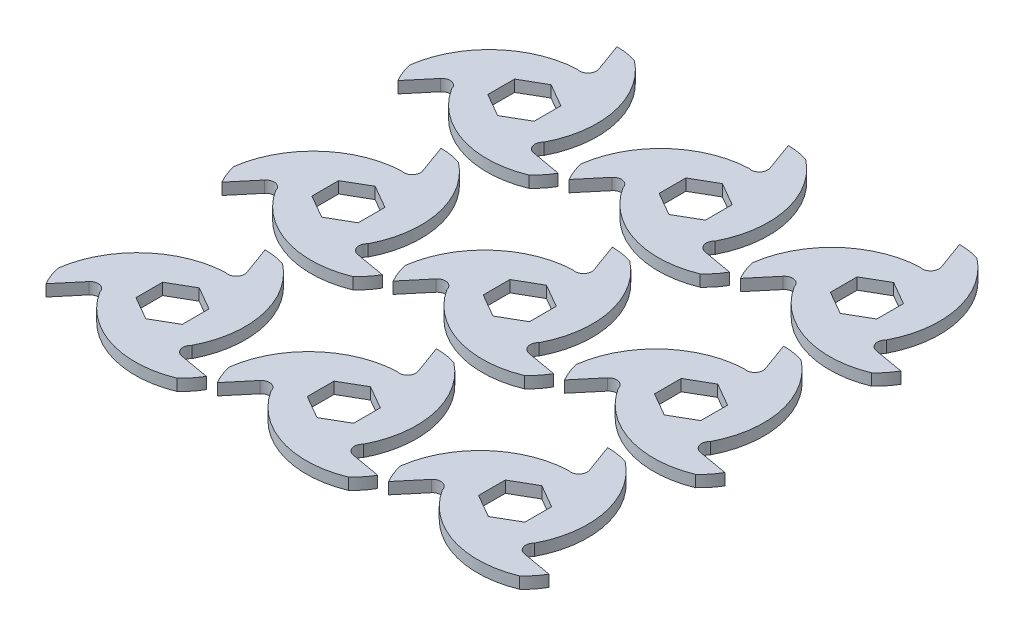
from build123d import *

# Parameters (mm, degrees)
BOSS_EXTRUDE2_DEPTH = 3.175
CUT_EXTRUDE1_DEPTH  = 7.35
LPATTERN1_COUNT     = 3
LPATTERN1_PITCH     = 96.52
LPATTERN1_2_COUNT   = 3
LPATTERN1_2_PITCH   = 93.98


with BuildPart() as part:
    # Sketch2 → Boss-Extrude2 (new body, symmetric)
    with BuildSketch(Plane(origin=(0, 0, 0), x_dir=(1, 0, 0), z_dir=(0, 1, 0))):
        with BuildLine():
            Line((0, 50.8), (5.699182497, 35.141624781))
            ThreePointArc((5.699182497, 35.141624781), (4.697625818, 30.400196659), (0, 29.21))
            ThreePointArc((0, 29.21), (-40.712457699, 16.982230342), (-43.994090512, -25.4))
            Line((-43.994090512, -25.4), (-33.283131039, -12.635175567))
            ThreePointArc((-33.283131039, -12.635175567), (-28.676155496, -11.131835033), (-25.296602045, -14.605))
            ThreePointArc((-25.296602045, -14.605), (5.64918596, -43.749137789), (43.994090512, -25.4))
            Line((43.994090512, -25.4), (27.583948542, -22.506449213))
            ThreePointArc((27.583948542, -22.506449213), (23.978529677, -19.268361626), (25.296602045, -14.605))
            ThreePointArc((25.296602045, -14.605), (35.063271738, 26.766907447), (0, 50.8))
        make_face()
        Polygon((0, 14.664696837), (12.7, 7.332348419), (12.7, -7.332348419), (0, -14.664696837), (-12.7, -7.332348419), (-12.7, 7.332348419), align=None, mode=Mode.SUBTRACT)
    extrude(amount=BOSS_EXTRUDE2_DEPTH, both=True)

    # Sketch3 → Cut-Extrude1 (cut, through all)
    with BuildSketch(Plane(origin=(0, 3.175, 0), x_dir=(1, 0, 0), z_dir=(0, 1, 0))):
        with BuildLine():
            ThreePointArc((0, 29.21), (-36.786884898, 21.158593478), (-48.137903328, -14.747595795))
            ThreePointArc((-48.137903328, -14.747595795), (-32.049598102, 15.970797155), (0, 29.21))
        make_face()
        with BuildLine():
            ThreePointArc((11.297159061, 49.062445064), (29.855915106, 19.77036756), (25.296602045, -14.605))
            ThreePointArc((25.296602045, -14.605), (36.717321909, 21.279080109), (11.297159061, 49.062445064))
        make_face()
        with BuildLine():
            ThreePointArc((-25.296602045, -14.605), (0.069562989, -42.437673587), (36.840744267, -34.314849269))
            ThreePointArc((36.840744267, -34.314849269), (2.193682996, -35.741164715), (-25.296602045, -14.605))
        make_face()
    extrude(amount=-CUT_EXTRUDE1_DEPTH, mode=Mode.SUBTRACT)


with BuildPart() as lpattern1_1:
    # LPattern1: pattern copy
    add(part.part.moved(Location(Vector(0, 0, 1) * (1 * LPATTERN1_PITCH))))


with BuildPart() as lpattern1_2:
    # LPattern1: pattern copy
    add(part.part.moved(Location(Vector(0, 0, 1) * (2 * LPATTERN1_PITCH))))


with BuildPart() as lpattern1_2_1:
    # LPattern1 2: pattern copy
    add(part.part.moved(Location(Vector(1, 0, 0) * (1 * LPATTERN1_2_PITCH))))


with BuildPart() as lpattern1_2_2:
    # LPattern1 2: pattern copy
    add(part.part.moved(Location(Vector(1, 0, 0) * (2 * LPATTERN1_2_PITCH))))


with BuildPart() as lpattern1_2_3:
    # LPattern1 2: pattern copy
    add(lpattern1_1.part.moved(Location(Vector(1, 0, 0) * (1 * LPATTERN1_2_PITCH))))


with BuildPart() as lpattern1_2_4:
    # LPattern1 2: pattern copy
    add(lpattern1_1.part.moved(Location(Vector(1, 0, 0) * (2 * LPATTERN1_2_PITCH))))


with BuildPart() as lpattern1_2_5:
    # LPattern1 2: pattern copy
    add(lpattern1_2.part.moved(Location(Vector(1, 0, 0) * (1 * LPATTERN1_2_PITCH))))


with BuildPart() as lpattern1_2_6:
    # LPattern1 2: pattern copy
    add(lpattern1_2.part.moved(Location(Vector(1, 0, 0) * (2 * LPATTERN1_2_PITCH))))


solid = Compound([part.part, lpattern1_1.part, lpattern1_2.part, lpattern1_2_1.part, lpattern1_2_2.part, lpattern1_2_3.part, lpattern1_2_4.part, lpattern1_2_5.part, lpattern1_2_6.part])
